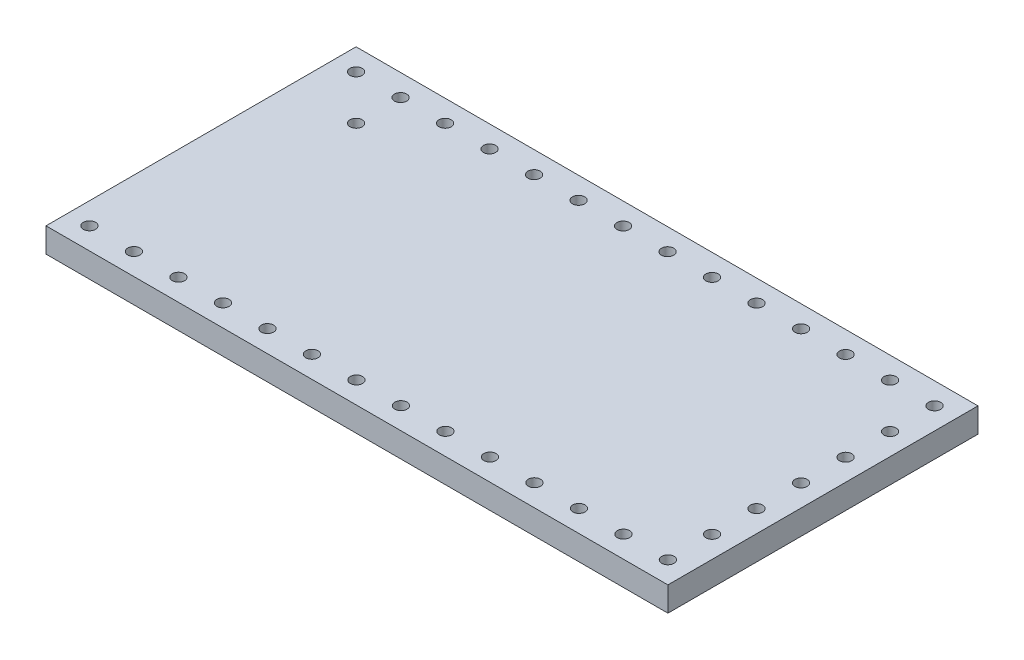
from build123d import *

# Parameters (mm, degrees)
SKETCH1_W           = 35.5
SKETCH1_H           = 17.7
SKETCH1_R           = 0.35
BOSS_EXTRUDE1_DEPTH = 1.4


with BuildPart() as part:
    # Sketch1 → Boss-Extrude1 (new body)
    with BuildSketch(Plane(origin=(0, 0, 0), x_dir=(1, 0, 0), z_dir=(0, 1, 0))):
        Rectangle(SKETCH1_W, SKETCH1_H)
        with Locations((-16.51, 7.61)):
            Circle(SKETCH1_R, mode=Mode.SUBTRACT)
        with Locations((-13.97, 7.61)):
            Circle(SKETCH1_R, mode=Mode.SUBTRACT)
        with Locations((-11.43, 7.61)):
            Circle(SKETCH1_R, mode=Mode.SUBTRACT)
        with Locations((-8.89, 7.61)):
            Circle(SKETCH1_R, mode=Mode.SUBTRACT)
        with Locations((-6.35, 7.61)):
            Circle(SKETCH1_R, mode=Mode.SUBTRACT)
        with Locations((-3.81, 7.61)):
            Circle(SKETCH1_R, mode=Mode.SUBTRACT)
        with Locations((-1.27, 7.61)):
            Circle(SKETCH1_R, mode=Mode.SUBTRACT)
        with Locations((1.27, 7.61)):
            Circle(SKETCH1_R, mode=Mode.SUBTRACT)
        with Locations((3.81, 7.61)):
            Circle(SKETCH1_R, mode=Mode.SUBTRACT)
        with Locations((6.35, 7.61)):
            Circle(SKETCH1_R, mode=Mode.SUBTRACT)
        with Locations((8.89, 7.61)):
            Circle(SKETCH1_R, mode=Mode.SUBTRACT)
        with Locations((11.43, 7.61)):
            Circle(SKETCH1_R, mode=Mode.SUBTRACT)
        with Locations((13.97, 7.61)):
            Circle(SKETCH1_R, mode=Mode.SUBTRACT)
        with Locations((16.51, 7.61)):
            Circle(SKETCH1_R, mode=Mode.SUBTRACT)
        with Locations((16.51, -7.61)):
            Circle(SKETCH1_R, mode=Mode.SUBTRACT)
        with Locations((13.97, -7.61)):
            Circle(SKETCH1_R, mode=Mode.SUBTRACT)
        with Locations((11.43, -7.61)):
            Circle(SKETCH1_R, mode=Mode.SUBTRACT)
        with Locations((8.89, -7.61)):
            Circle(SKETCH1_R, mode=Mode.SUBTRACT)
        with Locations((6.35, -7.61)):
            Circle(SKETCH1_R, mode=Mode.SUBTRACT)
        with Locations((3.81, -7.61)):
            Circle(SKETCH1_R, mode=Mode.SUBTRACT)
        with Locations((1.27, -7.61)):
            Circle(SKETCH1_R, mode=Mode.SUBTRACT)
        with Locations((-1.27, -7.61)):
            Circle(SKETCH1_R, mode=Mode.SUBTRACT)
        with Locations((-3.81, -7.61)):
            Circle(SKETCH1_R, mode=Mode.SUBTRACT)
        with Locations((-6.35, -7.61)):
            Circle(SKETCH1_R, mode=Mode.SUBTRACT)
        with Locations((-8.89, -7.61)):
            Circle(SKETCH1_R, mode=Mode.SUBTRACT)
        with Locations((-11.43, -7.61)):
            Circle(SKETCH1_R, mode=Mode.SUBTRACT)
        with Locations((-13.97, -7.61)):
            Circle(SKETCH1_R, mode=Mode.SUBTRACT)
        with Locations((-16.51, -7.61)):
            Circle(SKETCH1_R, mode=Mode.SUBTRACT)
        with Locations((-13.97, 5.07)):
            Circle(SKETCH1_R, mode=Mode.SUBTRACT)
        with Locations((16.51, 5.07)):
            Circle(SKETCH1_R, mode=Mode.SUBTRACT)
        with Locations((16.51, 2.53)):
            Circle(SKETCH1_R, mode=Mode.SUBTRACT)
        with Locations((16.51, -0.01)):
            Circle(SKETCH1_R, mode=Mode.SUBTRACT)
        with Locations((16.51, -2.55)):
            Circle(SKETCH1_R, mode=Mode.SUBTRACT)
        with Locations((16.51, -5.09)):
            Circle(SKETCH1_R, mode=Mode.SUBTRACT)
    extrude(amount=BOSS_EXTRUDE1_DEPTH)


solid = part.part
